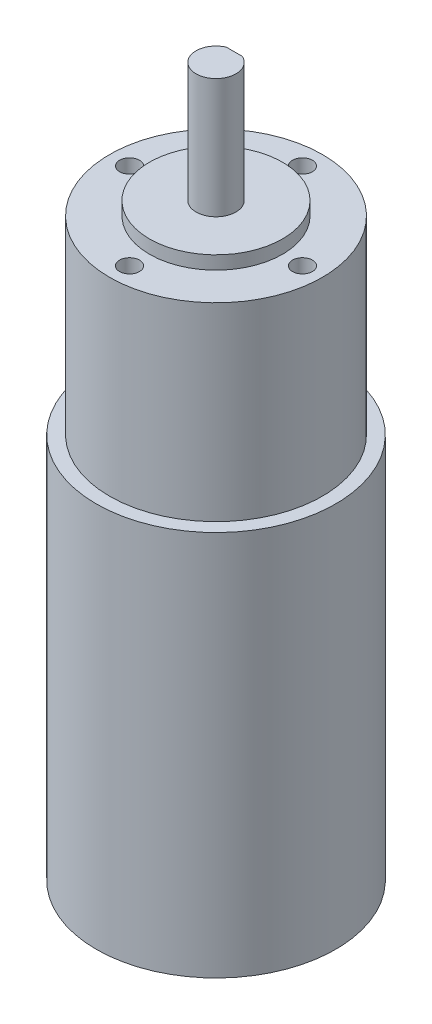
from build123d import *

# Parameters (mm, degrees)
ESQUISSE1_R                  = 18
BOSS_EXTRU_1_DEPTH           = 86.5
ESQUISSE2_R                  = 10
BOSS_EXTRU_2_DEPTH           = 2
ESQUISSE3_R                  = 3
BOSS_EXTRU_3_DEPTH           = 18
ENL_V_START                  = -15
ENL_V_MAT_EXTRU_1_DEPTH      = 15
ESQUISSE6_R                  = 1.5
ENL_V_MAT_EXTRU_2_DEPTH      = 10
R_P_TITION_CIRCULAIRE1_COUNT = 4
ENL_V_START_2                = -28.5
ESQUISSE7_R                  = 18
ESQUISSE7_R_2                = 16
ENL_V_MAT_EXTRU_3_DEPTH      = 28.5


with BuildPart() as part:
    # Esquisse1 → Boss.-Extru.1 (new body)
    with BuildSketch(Plane(origin=(0, 0, 0), x_dir=(1, 0, 0), z_dir=(0, 1, 0))):
        Circle(ESQUISSE1_R)
    extrude(amount=BOSS_EXTRU_1_DEPTH)

    # Esquisse2 → Boss.-Extru.2 (add)
    with BuildSketch(Plane(origin=(0, 86.5, 0), x_dir=(1, 0, 0), z_dir=(0, 1, 0))):
        Circle(ESQUISSE2_R)
    extrude(amount=BOSS_EXTRU_2_DEPTH)

    # Esquisse3 → Boss.-Extru.3 (add)
    with BuildSketch(Plane(origin=(0, 88.5, 0), x_dir=(1, 0, 0), z_dir=(0, 1, 0))):
        Circle(ESQUISSE3_R)
    extrude(amount=BOSS_EXTRU_3_DEPTH)

    # Esquisse4 → Enlèv. mat.-Extru.1 (cut)
    with BuildSketch(Plane(origin=(0, 106.5, 0), x_dir=(1, 0, 0), z_dir=(0, 1, 0)).offset(ENL_V_START)):
        with BuildLine():
            ThreePointArc((1.198957881, 2.75), (0, 3), (-1.198957881, 2.75))
            Line((-1.198957881, 2.75), (0, 2.75))
            Line((0, 2.75), (1.198957881, 2.75))
        make_face()
    extrude(amount=ENL_V_MAT_EXTRU_1_DEPTH, mode=Mode.SUBTRACT)

    # Esquisse6 → Enlèv. mat.-Extru.2 (cut)
    with BuildSketch(Plane(origin=(0, 86.5, 0), x_dir=(1, 0, 0), z_dir=(0, 1, 0))):
        with Locations((13, 0)):
            Circle(ESQUISSE6_R)
    enl_v_mat_extru_2 = extrude(amount=-ENL_V_MAT_EXTRU_2_DEPTH, mode=Mode.SUBTRACT)

    # Répétition circulaire1: Enlèv. mat.-Extru.2 ×4 about axis
    r_p_tition_circulaire1_axis = Axis((0, -10.575, 0), (0, 1, 0))
    for i in range(1, R_P_TITION_CIRCULAIRE1_COUNT):
        add(enl_v_mat_extru_2.rotate(r_p_tition_circulaire1_axis, i * 360 / R_P_TITION_CIRCULAIRE1_COUNT), mode=Mode.SUBTRACT)

    # Esquisse7 → Enlèv. mat.-Extru.3 (cut)
    with BuildSketch(Plane(origin=(0, 86.5, 0), x_dir=(1, 0, 0), z_dir=(0, 1, 0)).offset(ENL_V_START_2)):
        Circle(ESQUISSE7_R)
        Circle(ESQUISSE7_R_2, mode=Mode.SUBTRACT)
    extrude(amount=ENL_V_MAT_EXTRU_3_DEPTH, mode=Mode.SUBTRACT)


solid = part.part
